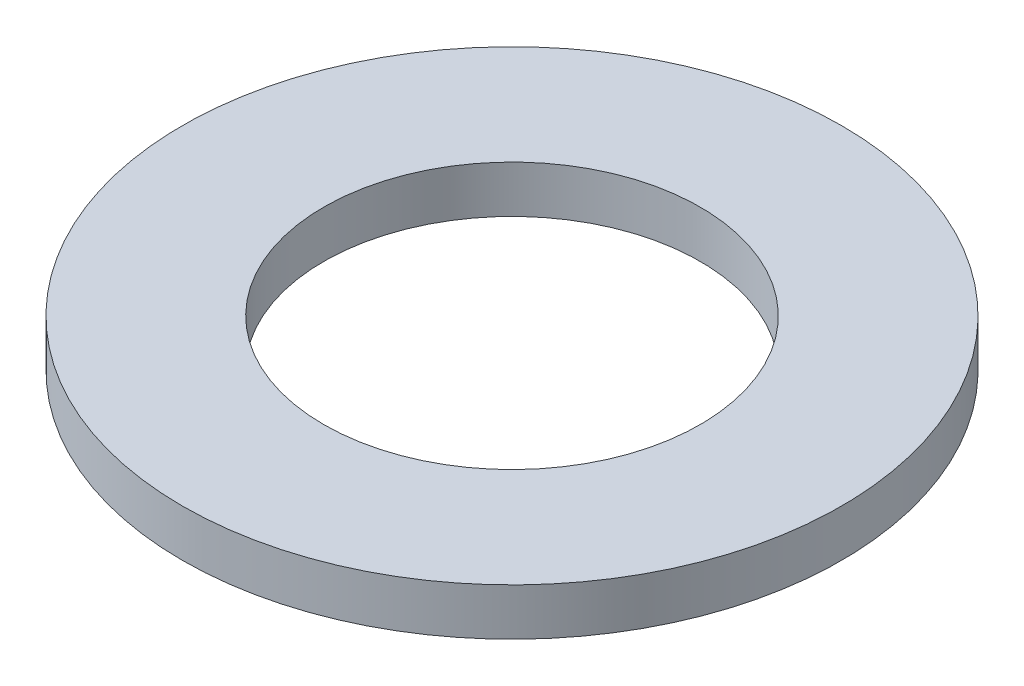
from build123d import *

# Parameters (mm, degrees)
SKETCH1_R           = 22.225
SKETCH1_R_2         = 12.7
BOSS_EXTRUDE1_DEPTH = 3.175


with BuildPart() as part:
    # Sketch1 → Boss-Extrude1 (new body)
    with BuildSketch(Plane(origin=(0, 0, 0), x_dir=(1, 0, 0), z_dir=(0, 1, 0))):
        with Locations(Location((0, 0, 0), (0, 0, 270))):  # turned: the seam where the file's is
            Circle(SKETCH1_R)
        with Locations(Location((0, 0, 0), (0, 0, 270))):  # turned: the seam where the file's is
            Circle(SKETCH1_R_2, mode=Mode.SUBTRACT)
    extrude(amount=BOSS_EXTRUDE1_DEPTH)


solid = part.part
